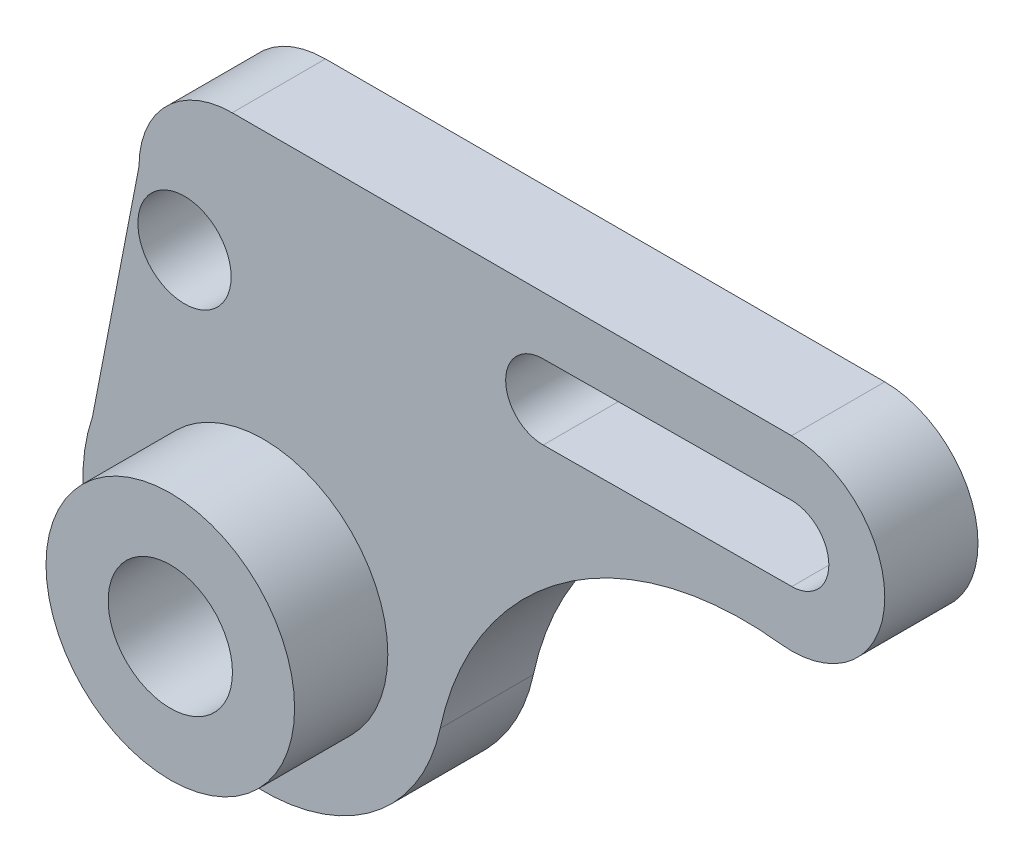
from build123d import *

# Parameters (mm, degrees)
BOSS_EXTRUDE2_DEPTH = 15
SKETCH2_R           = 20
BOSS_EXTRUDE3_DEPTH = 35
SKETCH3_R           = 10
CUT_EXTRUDE2_DEPTH  = 51
SKETCH6_R           = 20
CUT_EXTRUDE3_DEPTH  = 20
SKETCH7_R           = 7.5
CUT_EXTRUDE4_DEPTH  = 31


with BuildPart() as part:
    # Sketch1 → Boss-Extrude2 (new body)
    with BuildSketch(Plane.XY):
        with BuildLine():
            Line((84.958136085, 62.963493234), (-5.041863915, 62.963493234))
            ThreePointArc((-5.041863915, 62.963493234), (-15.648465633, 58.570094952), (-20.041863915, 47.963493234))
            Line((-20.041863915, 47.963493234), (-27.527219981, 9.333410593))
            ThreePointArc((-27.527219981, 9.333410593), (-7.728043394, -28.020309393), (28.419860478, -6.096878185))
            ThreePointArc((28.419860478, -6.096878185), (48.225361717, 24.087490733), (83.192615122, 33.067757746))
            ThreePointArc((83.192615122, 33.067757746), (99.932047269, 47.079194733), (84.958136085, 62.963493234))
        make_face()
        with BuildLine():
            ThreePointArc((45, 41.684539724), (38.958282136, 47.642529759), (44.91627217, 53.684247623))
            Line((44.91627217, 53.684247623), (84.91627217, 53.963347184))
            ThreePointArc((84.91627217, 53.963347184), (90.957990034, 48.005357149), (85, 41.963639285))
            Line((85, 41.963639285), (45, 41.684539724))
        make_face(mode=Mode.SUBTRACT)
    extrude(amount=BOSS_EXTRUDE2_DEPTH)

    # Sketch2 → Boss-Extrude3 (add)
    with BuildSketch(Plane.XY.offset(15)):
        Circle(SKETCH2_R)
    extrude(amount=BOSS_EXTRUDE3_DEPTH)

    # Sketch3 → Cut-Extrude2 (cut, through all)
    with BuildSketch(Plane.XY.offset(50)):
        Circle(SKETCH3_R)
    extrude(amount=-CUT_EXTRUDE2_DEPTH, mode=Mode.SUBTRACT)

    # Sketch6 → Cut-Extrude3 (cut)
    with BuildSketch(Plane.XY.offset(50)):
        Circle(SKETCH6_R)
    extrude(amount=-CUT_EXTRUDE3_DEPTH, mode=Mode.SUBTRACT)

    # Sketch7 → Cut-Extrude4 (cut, through all)
    with BuildSketch(Plane.XY.offset(30)):
        with Locations((-12.716641072, 40)):
            Circle(SKETCH7_R)
    extrude(amount=-CUT_EXTRUDE4_DEPTH, mode=Mode.SUBTRACT)


solid = part.part
